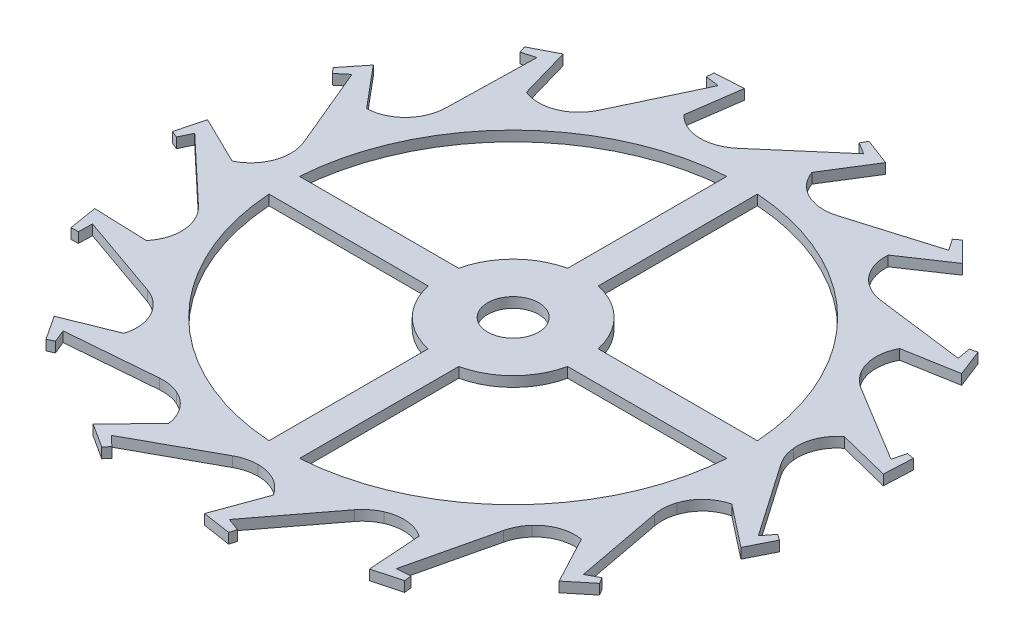
from build123d import *

# Parameters (mm, degrees)
BOSS_EXTRUDE1_DEPTH = 0.1
CUT_EXTRUDE1_REACH  = 2.1
SKETCH2_R           = 0.25


with BuildPart() as part:
    # Sketch1 → Boss-Extrude1 (new body)
    with BuildSketch(Plane(origin=(0, 0, 0), x_dir=(1, 0, 0), z_dir=(0, 1, 0))):
        with BuildLine():
            Line((-2.092809674, -2.32103661), (-1.220498963, -2.249243791))
            ThreePointArc((-1.220498963, -2.249243791), (-1.116490826, -2.253732669), (-1.016841608, -2.283863644))
            ThreePointArc((-1.016841608, -2.283863644), (-0.862981663, -2.406617422), (-0.788457807, -2.588791976))
            Line((-0.788457807, -2.588791976), (-1.153371274, -2.965953428))
            Line((-1.153371274, -2.965953428), (-0.91655705, -3.118080046))
            Line((-0.91655705, -3.118080046), (-0.870591181, -3.064950132))
            Line((-0.870591181, -3.064950132), (-0.967826132, -2.971594834))
            Line((-0.967826132, -2.971594834), (-0.200131415, -2.551208099))
            ThreePointArc((-0.200131415, -2.551208099), (-0.103289463, -2.513004973), (0, -2.5))
            ThreePointArc((0, -2.5), (0.190486514, -2.549560679), (0.332664509, -2.685673832))
            Line((0.332664509, -2.685673832), (0.152704852, -3.178651642))
            Line((0.152704852, -3.178651642), (0.430920881, -3.2213052))
            Line((0.430920881, -3.2213052), (0.451302909, -3.154072605))
            Line((0.451302909, -3.154072605), (0.324503341, -3.108337314))
            Line((0.324503341, -3.108337314), (0.854840673, -2.41204535))
            ThreePointArc((0.854840673, -2.41204535), (0.927771587, -2.337755888), (1.016841608, -2.283863644))
            ThreePointArc((1.016841608, -2.283863644), (1.211017841, -2.251661732), (1.39626611, -2.318178284))
            Line((1.39626611, -2.318178284), (1.432376923, -2.84173211))
            Line((1.432376923, -2.84173211), (1.703888677, -2.767537421))
            Line((1.703888677, -2.767537421), (1.695162626, -2.697827272))
            Line((1.695162626, -2.697827272), (1.560723238, -2.707620035))
            Line((1.560723238, -2.707620035), (1.762003043, -1.855818048))
            ThreePointArc((1.762003043, -1.855818048), (1.798412501, -1.758287571), (1.857862064, -1.672826516))
            ThreePointArc((1.857862064, -1.672826516), (2.022153182, -1.564430016), (2.218440616, -1.549848651))
            Line((2.218440616, -1.549848651), (2.46437801, -2.01345128))
            Line((2.46437801, -2.01345128), (2.682238641, -1.835237279))
            Line((2.682238641, -1.835237279), (2.645913325, -1.775103093))
            Line((2.645913325, -1.775103093), (2.527079908, -1.838730653))
            Line((2.527079908, -1.838730653), (2.364499079, -0.978702945))
            ThreePointArc((2.364499079, -0.978702945), (2.358091556, -0.87479536), (2.377641291, -0.772542486))
            ThreePointArc((2.377641291, -0.772542486), (2.483639867, -0.606694138), (2.657026585, -0.513536106))
            Line((2.657026585, -0.513536106), (3.070265752, -0.837026432))
            Line((3.070265752, -0.837026432), (3.196805177, -0.585607939))
            Line((3.196805177, -0.585607939), (3.139161573, -0.545447464))
            Line((3.139161573, -0.545447464), (3.056481505, -0.651908037))
            Line((3.056481505, -0.651908037), (2.558151744, 0.067638788))
            ThreePointArc((2.558151744, 0.067638788), (2.510035158, 0.159956916), (2.486304738, 0.261321158))
            ThreePointArc((2.486304738, 0.261321158), (2.515682656, 0.455944668), (2.63618852, 0.611571497))
            Line((2.63618852, 0.611571497), (3.145276652, 0.484127891))
            Line((3.145276652, 0.484127891), (3.158615056, 0.765278334))
            Line((3.158615056, 0.765278334), (3.089620266, 0.778520987))
            Line((3.089620266, 0.778520987), (3.057389682, 0.6476354))
            Line((3.057389682, 0.6476354), (2.309476732, 1.102285161))
            ThreePointArc((2.309476732, 1.102285161), (2.227970878, 1.167051188), (2.165063509, 1.25))
            ThreePointArc((2.165063509, 1.25), (2.11274106, 1.4397465), (2.15952951, 1.630932832))
            Line((2.15952951, 1.630932832), (2.676440646, 1.721572103))
            Line((2.676440646, 1.721572103), (2.574271696, 1.98384103))
            Line((2.574271696, 1.98384103), (2.505855547, 1.967876087))
            Line((2.505855547, 1.967876087), (2.529647407, 1.835196794))
            Line((2.529647407, 1.835196794), (1.661472212, 1.946336415))
            ThreePointArc((1.661472212, 1.946336415), (1.560670193, 1.972351707), (1.469463131, 2.022542486))
            ThreePointArc((1.469463131, 2.022542486), (1.34448734, 2.174603081), (1.309468229, 2.368291064))
            Line((1.309468229, 2.368291064), (1.744823737, 2.661340858))
            Line((1.744823737, 2.661340858), (1.544813374, 2.85937959))
            Line((1.544813374, 2.85937959), (1.488805639, 2.816967533))
            Line((1.488805639, 2.816967533), (1.564506115, 2.705435989))
            Line((1.564506115, 2.705435989), (0.726184053, 2.453848421))
            ThreePointArc((0.726184053, 2.453848421), (0.623515453, 2.436614698), (0.519779227, 2.445369002))
            ThreePointArc((0.519779227, 2.445369002), (0.343759545, 2.533451034), (0.232987996, 2.696150256))
            Line((0.232987996, 2.696150256), (0.511510953, 3.140939602))
            Line((0.511510953, 3.140939602), (0.248242785, 3.240505442))
            Line((0.248242785, 3.240505442), (0.214327711, 3.178979702))
            Line((0.214327711, 3.178979702), (0.328847502, 3.107880724))
            Line((0.328847502, 3.107880724), (-0.334667927, 2.537067742))
            ThreePointArc((-0.334667927, 2.537067742), (-0.421450773, 2.479564872), (-0.519779227, 2.445369002))
            ThreePointArc((-0.519779227, 2.445369002), (-0.716407398, 2.454242288), (-0.883777979, 2.557820574))
            Line((-0.883777979, 2.557820574), (-0.810246722, 3.077441353))
            Line((-0.810246722, 3.077441353), (-1.091251237, 3.061318464))
            Line((-1.091251237, 3.061318464), (-1.097209426, 2.991317401))
            Line((-1.097209426, 2.991317401), (-0.963671831, 2.972944648))
            Line((-0.963671831, 2.972944648), (-1.337652781, 2.181605003))
            ThreePointArc((-1.337652781, 2.181605003), (-1.393544331, 2.093775753), (-1.469463131, 2.022542486))
            ThreePointArc((-1.469463131, 2.022542486), (-1.652700994, 1.950672754), (-1.847730712, 1.977220479))
            Line((-1.847730712, 1.977220479), (-1.991905378, 2.481825538))
            Line((-1.991905378, 2.481825538), (-2.242058006, 2.352801712))
            Line((-2.242058006, 2.352801712), (-2.219029085, 2.286429145))
            Line((-2.219029085, 2.286429145), (-2.08956355, 2.323959433))
            Line((-2.08956355, 2.323959433), (-2.109345317, 1.448922939))
            ThreePointArc((-2.109345317, 1.448922939), (-2.124681415, 1.345953785), (-2.165063509, 1.25))
            ThreePointArc((-2.165063509, 1.25), (-2.303227573, 1.10981418), (-2.492194019, 1.054741))
            Line((-2.492194019, 1.054741), (-2.829145498, 1.45707954))
            Line((-2.829145498, 1.45707954), (-3.005192577, 1.23746417))
            Line((-3.005192577, 1.23746417), (-2.957158456, 1.186196519))
            Line((-2.957158456, 1.186196519), (-2.854150748, 1.27314052))
            Line((-2.854150748, 1.27314052), (-2.516312885, 0.465708936))
            ThreePointArc((-2.516312885, 0.465708936), (-2.48844178, 0.36540418), (-2.486304738, 0.261321158))
            ThreePointArc((-2.486304738, 0.261321158), (-2.555505181, 0.077058651), (-2.70573434, -0.05011278))
            Line((-2.70573434, -0.05011278), (-3.17720066, 0.180391252))
            Line((-3.17720066, 0.180391252), (-3.248702051, -0.091842169))
            Line((-3.248702051, -0.091842169), (-3.183968265, -0.119140262))
            Line((-3.183968265, -0.119140262), (-3.125229353, 0.002184045))
            Line((-3.125229353, 0.002184045), (-2.488187096, -0.598030373))
            ThreePointArc((-2.488187096, -0.598030373), (-2.421927955, -0.678327127), (-2.377641291, -0.772542486))
            ThreePointArc((-2.377641291, -0.772542486), (-2.365912728, -0.969021018), (-2.451428612, -1.146301605))
            Line((-2.451428612, -1.146301605), (-2.975888963, -1.127488322))
            Line((-2.975888963, -1.127488322), (-2.930481426, -1.405268163))
            Line((-2.930481426, -1.405268163), (-2.860241036, -1.403876609))
            Line((-2.860241036, -1.403876609), (-2.85592741, -1.269150071))
            Line((-2.85592741, -1.269150071), (-2.029831153, -1.558364797))
            ThreePointArc((-2.029831153, -1.558364797), (-1.936640783, -1.604769512), (-1.857862064, -1.672826516))
            ThreePointArc((-1.857862064, -1.672826516), (-1.767232469, -1.84754815), (-1.773248606, -2.044284468))
            Line((-1.773248606, -2.044284468), (-2.26001903, -2.240414922))
            Line((-2.26001903, -2.240414922), (-2.105553941, -2.475710525))
            Line((-2.105553941, -2.475710525), (-2.041952147, -2.445869936))
            Line((-2.041952147, -2.445869936), (-2.092809674, -2.32103661))
        make_face()
    extrude(amount=BOSS_EXTRUDE1_DEPTH)

    # Sketch2 → Cut-Extrude1 (cut, up to next)
    with BuildSketch(Plane(origin=(0, 0, 0), x_dir=(1, 0, 0), z_dir=(0, 1, 0)), mode=Mode.PRIVATE) as cut_extrude1_sk1:
        Circle(SKETCH2_R)
    cut_extrude1_tool1 = extrude(cut_extrude1_sk1.sketch, amount=CUT_EXTRUDE1_REACH, mode=Mode.PRIVATE) & part.part
    add(cut_extrude1_tool1.solids().sort_by_distance((0, 0, 0))[0], mode=Mode.SUBTRACT)
    # Sketch2 → Cut-Extrude1 (cut, up to next)
    with BuildSketch(Plane(origin=(0, 0, 0), x_dir=(1, 0, 0), z_dir=(0, 1, 0)), mode=Mode.PRIVATE) as cut_extrude1_sk2:
        with BuildLine():
            Line((0.15, 2.244994432), (0.15, 0.683739717))
            ThreePointArc((0.15, 0.683739717), (0.494974747, 0.494974747), (0.683739717, 0.15))
            Line((0.683739717, 0.15), (2.244994432, 0.15))
            ThreePointArc((2.244994432, 0.15), (1.590990258, 1.590990258), (0.15, 2.244994432))
        make_face()
    cut_extrude1_tool2 = extrude(cut_extrude1_sk2.sketch, amount=CUT_EXTRUDE1_REACH, mode=Mode.PRIVATE) & part.part
    add(cut_extrude1_tool2.solids().sort_by_distance((1.063034, 0, -1.063034))[0], mode=Mode.SUBTRACT)
    # Sketch2 → Cut-Extrude1 (cut, up to next)
    with BuildSketch(Plane(origin=(0, 0, 0), x_dir=(1, 0, 0), z_dir=(0, 1, 0)), mode=Mode.PRIVATE) as cut_extrude1_sk3:
        with BuildLine():
            Line((-0.15, -2.244994432), (-0.15, -0.683739717))
            ThreePointArc((-0.15, -0.683739717), (-0.494974747, -0.494974747), (-0.683739717, -0.15))
            Line((-0.683739717, -0.15), (-2.244994432, -0.15))
            ThreePointArc((-2.244994432, -0.15), (-1.590990258, -1.590990258), (-0.15, -2.244994432))
        make_face()
    cut_extrude1_tool3 = extrude(cut_extrude1_sk3.sketch, amount=CUT_EXTRUDE1_REACH, mode=Mode.PRIVATE) & part.part
    add(cut_extrude1_tool3.solids().sort_by_distance((-1.063034, 0, 1.063034))[0], mode=Mode.SUBTRACT)
    # Sketch2 → Cut-Extrude1 (cut, up to next)
    with BuildSketch(Plane(origin=(0, 0, 0), x_dir=(1, 0, 0), z_dir=(0, 1, 0)), mode=Mode.PRIVATE) as cut_extrude1_sk4:
        with BuildLine():
            Line((-2.244994432, 0.15), (-0.683739717, 0.15))
            ThreePointArc((-0.683739717, 0.15), (-0.494974747, 0.494974747), (-0.15, 0.683739717))
            Line((-0.15, 0.683739717), (-0.15, 2.244994432))
            ThreePointArc((-0.15, 2.244994432), (-1.590990258, 1.590990258), (-2.244994432, 0.15))
        make_face()
    cut_extrude1_tool4 = extrude(cut_extrude1_sk4.sketch, amount=CUT_EXTRUDE1_REACH, mode=Mode.PRIVATE) & part.part
    add(cut_extrude1_tool4.solids().sort_by_distance((-1.063034, 0, -1.063034))[0], mode=Mode.SUBTRACT)
    # Sketch2 → Cut-Extrude1 (cut, up to next)
    with BuildSketch(Plane(origin=(0, 0, 0), x_dir=(1, 0, 0), z_dir=(0, 1, 0)), mode=Mode.PRIVATE) as cut_extrude1_sk5:
        with BuildLine():
            Line((0.15, -0.683739717), (0.15, -2.244994432))
            ThreePointArc((0.15, -2.244994432), (1.590990258, -1.590990258), (2.244994432, -0.15))
            Line((2.244994432, -0.15), (0.683739717, -0.15))
            ThreePointArc((0.683739717, -0.15), (0.494974747, -0.494974747), (0.15, -0.683739717))
        make_face()
    cut_extrude1_tool5 = extrude(cut_extrude1_sk5.sketch, amount=CUT_EXTRUDE1_REACH, mode=Mode.PRIVATE) & part.part
    add(cut_extrude1_tool5.solids().sort_by_distance((1.063034, 0, 1.063034))[0], mode=Mode.SUBTRACT)


solid = part.part
